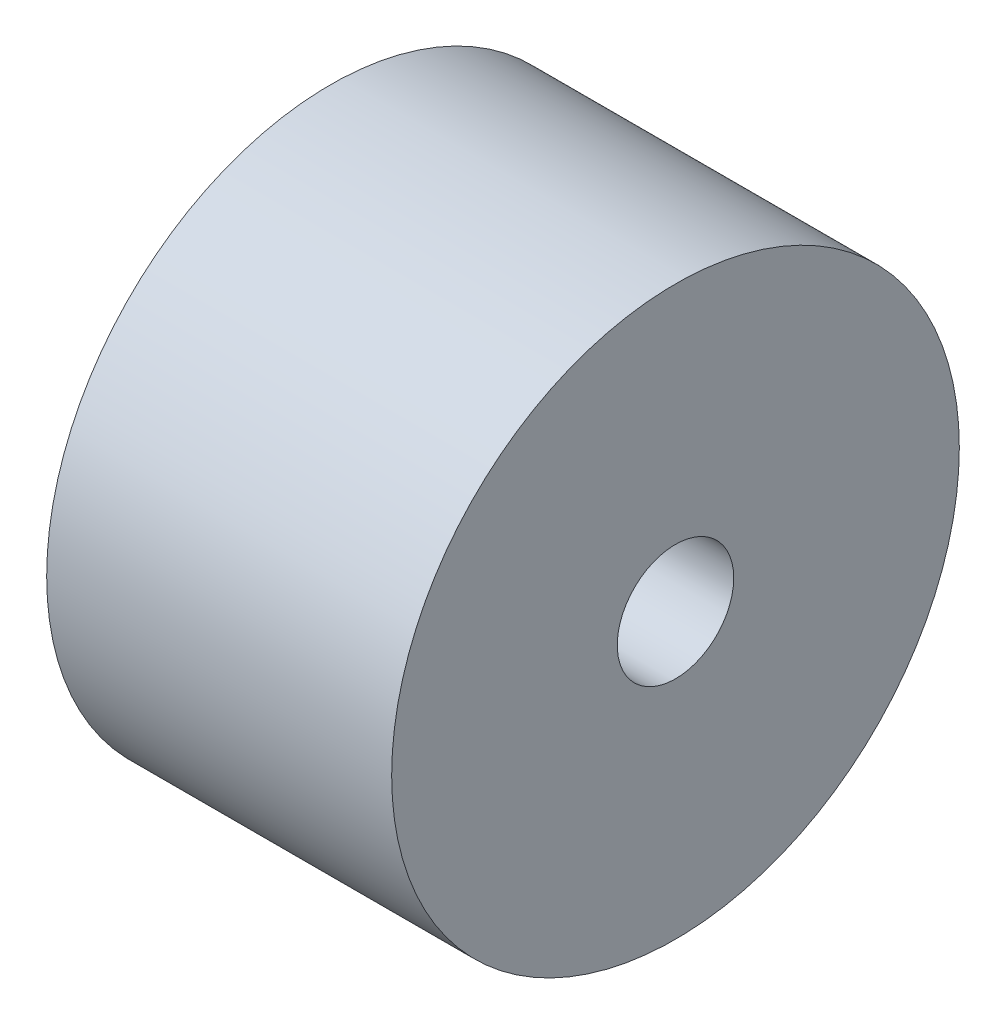
from build123d import *

# Parameters (mm, degrees)
SKETCH1_W          = 22
SKETCH1_H          = 18.1
SKETCH2_R          = 3.71375
CUT_EXTRUDE1_DEPTH = 8.5725
SKETCH4_R          = 3.71375
CUT_EXTRUDE2_DEPTH = 8.5725


with BuildPart() as part:
    # Sketch1 → Revolve1 (revolve)
    with BuildSketch(Plane.XY):
        with Locations((19.255, 9.05)):
            Rectangle(SKETCH1_W, SKETCH1_H)
    revolve(axis=Axis((8.255, 0, 0), (1, 0, 0)))

    # Sketch2 → Cut-Extrude1 (cut)
    with BuildSketch(Plane.ZY.offset(-8.255)):
        Circle(SKETCH2_R)
    extrude(amount=-CUT_EXTRUDE1_DEPTH, mode=Mode.SUBTRACT)

    # Sketch4 → Cut-Extrude2 (cut)
    with BuildSketch(Plane(origin=(30.255, 0, 0), x_dir=(0, 0, -1), z_dir=(1, 0, 0))):
        Circle(SKETCH4_R)
    extrude(amount=-CUT_EXTRUDE2_DEPTH, mode=Mode.SUBTRACT)


solid = part.part
